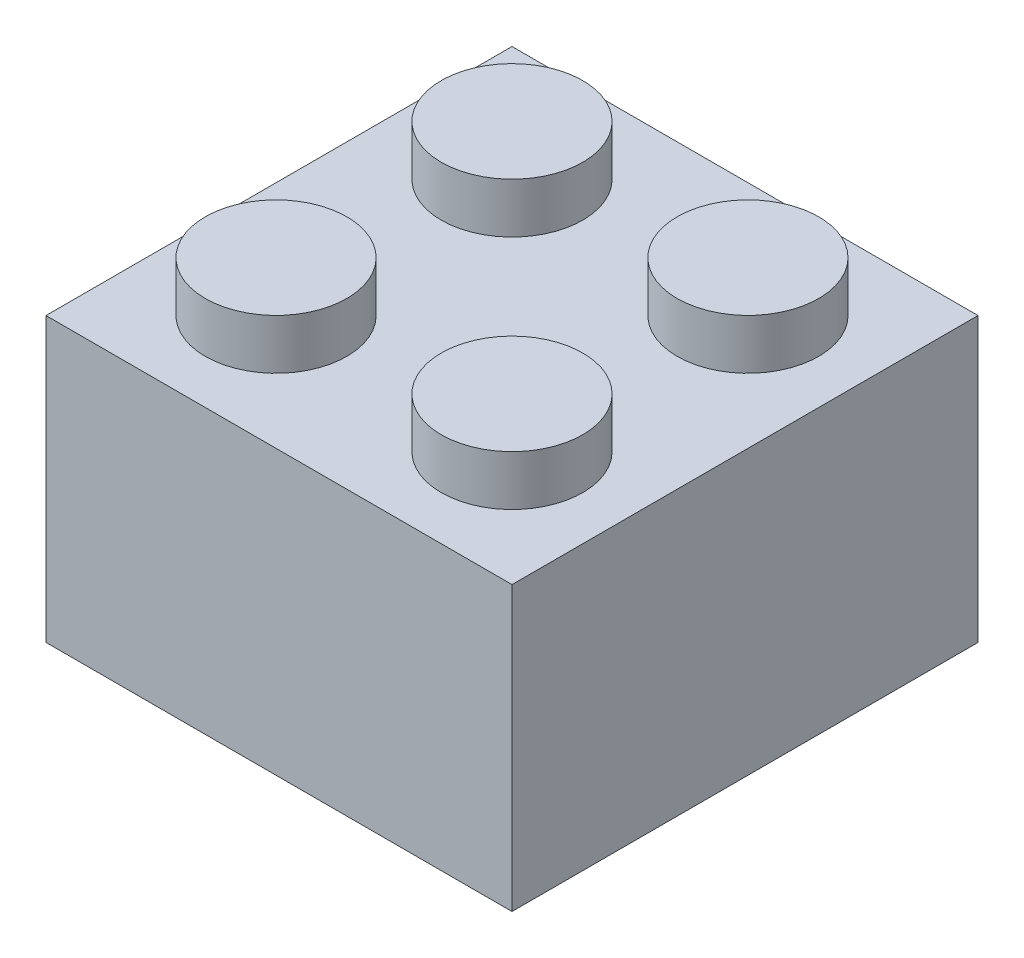
from build123d import *

# Parameters (mm, degrees)
SKETCH_1_W          = 15.8
SKETCH_1_H          = 15.8
EXTRUDE_1_DEPTH     = 9.6
SKETCH_2_R          = 2.4
EXTRUDE_2_DEPTH     = 1.7
SKETCH_3_R          = 2.5
CUT_EXTRUDE_2_DEPTH = 1.8


with BuildPart() as part:
    # Эскиз1 → Бобышка-Вытянуть1 (new body)
    with BuildSketch(Plane(origin=(0, 0, 0), x_dir=(1, 0, 0), z_dir=(0, 1, 0))):
        with Locations((7.9, 7.9)):
            Rectangle(SKETCH_1_W, SKETCH_1_H)
    extrude(amount=EXTRUDE_1_DEPTH)

    # Эскиз2 → Бобышка-Вытянуть2 (add)
    with BuildSketch(Plane(origin=(0, 9.6, 0), x_dir=(1, 0, 0), z_dir=(0, 1, 0))):
        with Locations((3.9, 11.9)):
            Circle(SKETCH_2_R)
        with Locations((11.9, 11.9)):
            Circle(SKETCH_2_R)
        with Locations((11.9, 3.9)):
            Circle(SKETCH_2_R)
        with Locations((3.9, 3.9)):
            Circle(SKETCH_2_R)
    extrude(amount=EXTRUDE_2_DEPTH)

    # Эскиз3 → Вырез-Вытянуть2 (cut)
    with BuildSketch(Plane.XZ):
        with Locations((11.9, -3.9)):
            Circle(SKETCH_3_R)
        with Locations((3.9, -3.9)):
            Circle(SKETCH_3_R)
        with Locations((3.9, -11.9)):
            Circle(SKETCH_3_R)
        with Locations((11.9, -11.9)):
            Circle(SKETCH_3_R)
    extrude(amount=-CUT_EXTRUDE_2_DEPTH, mode=Mode.SUBTRACT)


solid = part.part
